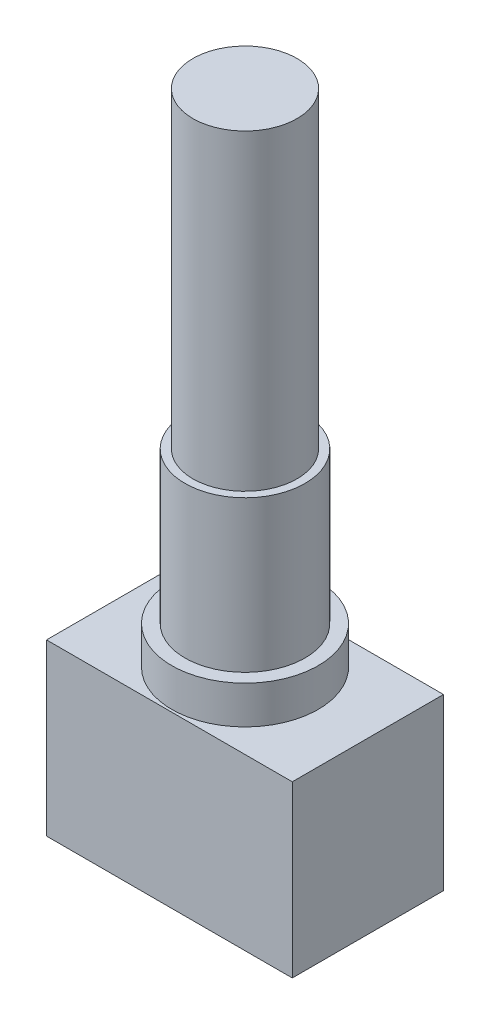
from build123d import *

# Parameters (mm, degrees)
SKETCH2_W           = 13.0048
SKETCH2_H           = 8.9916
BOSS_EXTRUDE1_DEPTH = 4.0005
SKETCH4_R           = 2.7559
BOSS_EXTRUDE2_DEPTH = 16.51


with BuildPart() as part:
    # Sketch2 → Boss-Extrude1 (new body, symmetric)
    with BuildSketch(Plane.XY):
        with Locations((0, -4.4958)):
            Rectangle(SKETCH2_W, SKETCH2_H)
    extrude(amount=BOSS_EXTRUDE1_DEPTH, both=True)

    # Sketch3 → Revolve2 (revolve)
    with BuildSketch(Plane.XY):
        Polygon((-3.175, 10.0076), (-3.175, 2.0066), (-3.875, 2.0066), (-3.875, 0), (0, 0), (0, 10.0076), align=None)
    revolve(axis=Axis((0, 0, 0), (0, 1, 0)))

    # Sketch4 → Boss-Extrude2 (add)
    with BuildSketch(Plane(origin=(0, 10.0076, 0), x_dir=(1, 0, 0), z_dir=(0, 1, 0))):
        Circle(SKETCH4_R)
    extrude(amount=BOSS_EXTRUDE2_DEPTH)


solid = part.part
